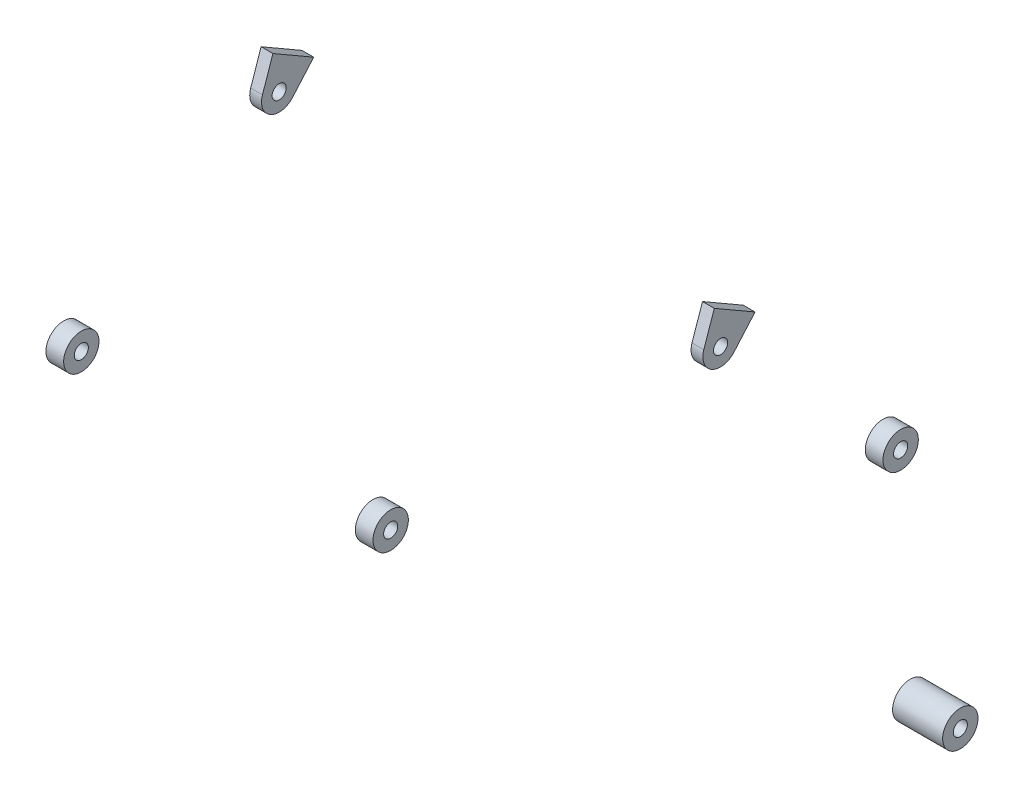
from build123d import *

# Parameters (mm, degrees)
SKETCH2_R           = 6
BOSS_EXTRUDE1_DEPTH = 10
SKETCH3_R           = 15
SKETCH3_R_2         = 6
BOSS_EXTRUDE2_DEPTH = 15
SKETCH5_R           = 15
SKETCH5_R_2         = 6
BOSS_EXTRUDE3_DEPTH = 42.5
BOSS_EXTRUDE4_DEPTH = 15


with BuildPart() as part:
    # Sketch2 → Boss-Extrude1 (new body)
    with BuildSketch(Plane(origin=(0, 0, 0), x_dir=(0, 0, -1), z_dir=(1, 0, 0))):
        with BuildLine():
            Line((-5.320508076, 30.784609691), (29.320508076, 10.784609691))
            Line((29.320508076, 10.784609691), (11.301534141, -9.862825461))
            ThreePointArc((11.301534141, -9.862825461), (-7.5, -12.990381057), (-14.192224472, 4.856002937))
            Line((-14.192224472, 4.856002937), (-5.320508076, 30.784609691))
        make_face()
        Circle(SKETCH2_R, mode=Mode.SUBTRACT)
    extrude(amount=BOSS_EXTRUDE1_DEPTH)


with BuildPart() as body_2:
    # Sketch3 → Boss-Extrude2 (new body)
    with BuildSketch(Plane(origin=(-43.5, 0, 0), x_dir=(0, 0, -1), z_dir=(1, 0, 0))):
        with Locations((-226.385122131, -48.394488094)):
            Circle(SKETCH3_R)
        with Locations((-226.385122131, -48.394488094)):
            Circle(SKETCH3_R_2, mode=Mode.SUBTRACT)
    extrude(amount=-BOSS_EXTRUDE2_DEPTH)


with BuildPart() as body_3:
    # Sketch5 → Boss-Extrude3 (new body)
    with BuildSketch(Plane(origin=(-72.5, 0, 0), x_dir=(0, 0, -1), z_dir=(1, 0, 0))):
        with Locations((243.45711943, -422.357745708)):
            Circle(SKETCH5_R)
        with Locations((243.45711943, -422.357745708)):
            Circle(SKETCH5_R_2, mode=Mode.SUBTRACT)
    extrude(amount=BOSS_EXTRUDE3_DEPTH)


with BuildPart() as body_4:
    # Sketch7 → Boss-Extrude4 (new body)
    with BuildSketch(Plane(origin=(-51.5, 0, 0), x_dir=(0, 0, -1), z_dir=(1, 0, 0))):
        with BuildLine():
            Line((193.683194113, -196.761801503), (185.196965502, -193.76448204))
            ThreePointArc((185.196965502, -193.76448204), (187.995008135, -208.572034313), (202.24424464, -213.476308561))
            Line((202.24424464, -213.476308561), (200.502105768, -204.646532111))
            ThreePointArc((200.502105768, -204.646532111), (194.802411166, -202.684822412), (193.683194113, -196.761801503))
        make_face()
        with BuildLine():
            ThreePointArc((214.340679854, -198.760014478), (205.070823115, -184.897638845), (188.71861876, -188.168894701))
            Line((188.71861876, -188.168894701), (195.091855416, -194.523566568))
            ThreePointArc((195.091855416, -194.523566568), (201.632737158, -193.215064225), (205.340679854, -198.760014478))
            ThreePointArc((205.340679854, -198.760014478), (203.975793417, -202.569964905), (200.502105768, -204.646532111))
            Line((200.502105768, -204.646532111), (202.24424464, -213.476308561))
            ThreePointArc((202.24424464, -213.476308561), (210.928463762, -208.284890546), (214.340679854, -198.760014478))
        make_face()
        with BuildLine():
            ThreePointArc((188.71861876, -188.168894701), (186.645658871, -190.770243378), (185.196965502, -193.76448204))
            Line((185.196965502, -193.76448204), (193.683194113, -196.761801503))
            ThreePointArc((193.683194113, -196.761801503), (194.26267146, -195.564106038), (195.091855416, -194.523566568))
            Line((195.091855416, -194.523566568), (188.71861876, -188.168894701))
        make_face()
    extrude(amount=BOSS_EXTRUDE4_DEPTH)


with BuildPart() as body_5:
    # Mirror5: mirrored copy
    add(body_2.part.mirror(Plane.ZY.offset(182.25)))


with BuildPart() as body_6:
    # Mirror5 2: mirrored copy
    add(part.part.mirror(Plane.ZY.offset(182.25)))


solid = Compound([part.part, body_2.part, body_3.part, body_4.part, body_5.part, body_6.part])
